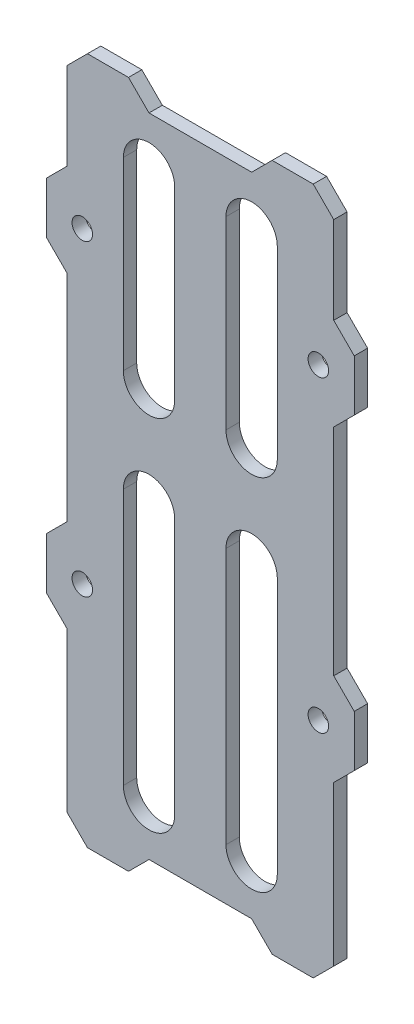
from build123d import *

# Parameters (mm, degrees)
SKICA1_W                 = 30
SKICA1_H                 = 67
SKICA1_R                 = 1
P_IDAT_VYSUNUT_M1_DEPTH  = 1.3
ODEBRAT_VYSUNUT_M1_DEPTH = 1.3
ZKOSEN_1_SIZE            = 2
SCALA1_SCALE             = 0.64


with BuildPart() as part:
    # Skica1 → Přidat vysunutím1 (new body)
    with BuildSketch(Plane.XY):
        with Locations((0, -3.5)):
            Rectangle(SKICA1_W, SKICA1_H)
        with Locations((-11.5, 15)):
            Circle(SKICA1_R, mode=Mode.SUBTRACT)
        with Locations((-11.5, -15)):
            Circle(SKICA1_R, mode=Mode.SUBTRACT)
        with Locations((11.5, -15)):
            Circle(SKICA1_R, mode=Mode.SUBTRACT)
        with Locations((11.5, 15)):
            Circle(SKICA1_R, mode=Mode.SUBTRACT)
    extrude(amount=P_IDAT_VYSUNUT_M1_DEPTH)

    # Skica2 → Odebrat vysunutím1 (cut)
    with BuildSketch(Plane.XY.offset(1.3)):
        Polygon((-15, 12.5), (-15, 17.5), (-15, 30), (-13, 30), (-7, 30), (0, 30), (0, 36.174813822), (-21.495608396, 36.174813822), (-21.495608396, -40.537143206), (0, -40.537143206), (0, -37), (-7, -37), (-13, -37), (-15, -37), (-15, -17.5), (-15, -12.5), align=None)
        Polygon((0, 36.174813822), (0, 30), (7, 30), (13, 30), (15, 30), (15, 17.5), (15, 12.5), (15, -12.5), (15, -17.5), (15, -37), (13, -37), (7, -37), (0, -37), (0, -40.537143206), (21.495608396, -40.537143206), (21.495608396, 36.174813822), align=None)
        Polygon((15, 30), (13, 30), (13, 19.5), (15, 17.5), align=None)
        Polygon((15, -12.5), (15, 12.5), (13, 10.5), (13, -10.5), align=None)
        Polygon((13, -19.5), (13, -37), (15, -37), (15, -17.5), align=None)
        Polygon((0, -35), (0, -37), (7, -37), (5, -35), align=None)
        Polygon((-5, -35), (-7, -37), (0, -37), (0, -35), align=None)
        Polygon((-13, -19.5), (-15, -17.5), (-15, -37), (-13, -37), align=None)
        Polygon((-13, 10.5), (-15, 12.5), (-15, -12.5), (-13, -10.5), align=None)
        Polygon((-15, 30), (-15, 17.5), (-13, 19.5), (-13, 30), align=None)
        Polygon((7, 30), (0, 30), (0, 28), (5, 28), align=None)
        Polygon((0, 30), (-7, 30), (-5, 28), (0, 28), align=None)
        with BuildLine():
            Line((-7.5, 23), (-7.5, 5))
            ThreePointArc((-7.5, 5), (-5, 2.5), (-2.5, 5))
            Line((-2.5, 5), (-2.5, 23))
            ThreePointArc((-2.5, 23), (-5, 25.5), (-7.5, 23))
        make_face()
        with BuildLine():
            ThreePointArc((7.5, 5), (5, 2.5), (2.5, 5))
            Line((2.5, 5), (2.5, 23))
            ThreePointArc((2.5, 23), (5, 25.5), (7.5, 23))
            Line((7.5, 23), (7.5, 5))
        make_face()
        with BuildLine():
            ThreePointArc((7.5, -30), (5, -32.5), (2.5, -30))
            Line((2.5, -30), (2.5, -5))
            ThreePointArc((2.5, -5), (5, -2.5), (7.5, -5))
            Line((7.5, -5), (7.5, -30))
        make_face()
        with BuildLine():
            Line((-7.5, -5), (-7.5, -30))
            ThreePointArc((-7.5, -30), (-5, -32.5), (-2.5, -30))
            Line((-2.5, -30), (-2.5, -5))
            ThreePointArc((-2.5, -5), (-5, -2.5), (-7.5, -5))
        make_face()
    extrude(amount=-ODEBRAT_VYSUNUT_M1_DEPTH, mode=Mode.SUBTRACT)

    # Zkosení1
    zkosen_1_edges = [part.edges().sort_by_distance(p)[0] for p in [
        (13, 30, 0.65),
        (-13, 30, 0.65),
        (-13, -37, 0.65),
        (13, -37, 0.65),
    ]]
    chamfer(zkosen_1_edges, length=ZKOSEN_1_SIZE)


with BuildPart() as part_1:
    # Scala1: scaled about (0, -3.201388425, 0.65)
    add(part.part.scale(SCALA1_SCALE).moved(Location((0, -1.152499833, 0.234))))


solid = part_1.part
